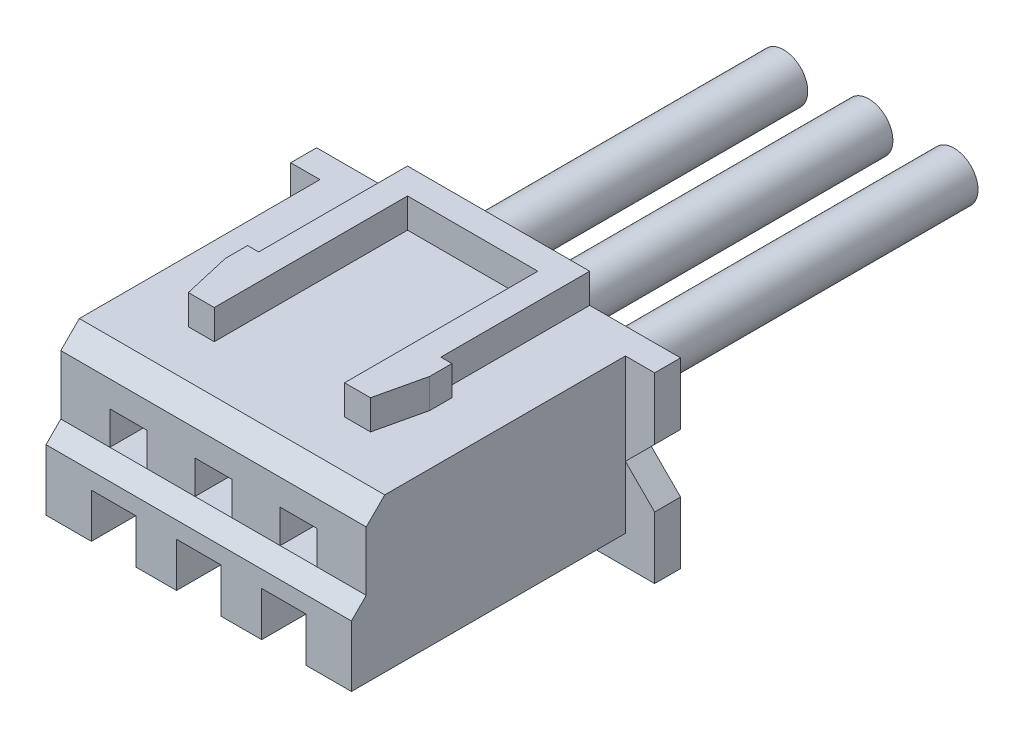
from build123d import *

# Parameters (mm, degrees)
ESQUISSE1_W               = 8.25
ESQUISSE1_H               = 4.15
ESQUISSE1_W_2             = 1
ESQUISSE1_H_2             = 0.9
BOSS_EXTRU_1_DEPTH        = 8.1
ESQUISSE2_W               = 5.6
ESQUISSE2_H               = 0.9
BOSS_EXTRU_2_DEPTH        = 0.7
ENL_V_MAT_EXTRU_1_DEPTH   = 6.6
ENL_V_MAT_EXTRU_2_DEPTH   = 10.04
ESQUISSE6_W               = 1.2
ESQUISSE6_H               = 1.2
ENL_V_MAT_EXTRU_3_DEPTH   = 3.1
BOSS_EXTRU_3_DEPTH        = 0.8
ESQUISSE8_R               = 0.65
BOSS_EXTRU_4_DEPTH        = 10
BOSS_EXTRU_4_DEPTH_BACK   = 2
BOSS_EXTRU_4_2_DEPTH      = 10
BOSS_EXTRU_4_2_DEPTH_BACK = 2
BOSS_EXTRU_4_3_DEPTH      = 10
BOSS_EXTRU_4_3_DEPTH_BACK = 2


with BuildPart() as part:
    # Esquisse1 → Boss.-Extru.1 (new body)
    with BuildSketch(Plane.XY):
        with Locations((0, -0.425)):
            Rectangle(ESQUISSE1_W, ESQUISSE1_H)
        Rectangle(ESQUISSE1_W_2, ESQUISSE1_H_2, mode=Mode.SUBTRACT)
        with Locations((-2.3, 0)):
            Rectangle(ESQUISSE1_W_2, ESQUISSE1_H_2, mode=Mode.SUBTRACT)
        with Locations((2.3, 0)):
            Rectangle(ESQUISSE1_W_2, ESQUISSE1_H_2, mode=Mode.SUBTRACT)
    extrude(amount=-BOSS_EXTRU_1_DEPTH)

    # Esquisse2 → Boss.-Extru.2 (add)
    with BuildSketch(Plane(origin=(0, 0, -8.1), x_dir=(-1, 0, 0), z_dir=(0, 0, -1))):
        Polygon((-4.915, 1.65), (4.915, 1.65), (4.915, -3.28), (-4.915, -3.28), (-4.915, -1.605), (-4.125, -0.815), (-4.915, -0.025), align=None)
        Rectangle(ESQUISSE2_W, ESQUISSE2_H, mode=Mode.SUBTRACT)
    extrude(amount=-BOSS_EXTRU_2_DEPTH)

    # Esquisse3 → Enlèv. mat.-Extru.1 (cut)
    with BuildSketch(Plane(origin=(0, 0, -8.1), x_dir=(-1, 0, 0), z_dir=(0, 0, -1))):
        Polygon((0.5, -1.6), (0.95, -1.6), (0.95, 1.05), (-0.95, 1.05), (-0.95, -1.6), (-0.5, -1.6), (-0.5, -1.9), (0.5, -1.9), align=None)
        Polygon((-1.8, -1.6), (-1.35, -1.6), (-1.35, 1.05), (-3.25, 1.05), (-3.25, -1.6), (-2.8, -1.6), (-2.8, -1.9), (-1.8, -1.9), align=None)
        Polygon((2.8, -1.6), (3.25, -1.6), (3.25, 1.05), (1.35, 1.05), (1.35, -1.6), (1.8, -1.6), (1.8, -1.9), (2.8, -1.9), align=None)
    extrude(amount=-ENL_V_MAT_EXTRU_1_DEPTH, mode=Mode.SUBTRACT)

    # Esquisse4 → Enlèv. mat.-Extru.2 (cut, through all)
    with BuildSketch(Plane(origin=(4.125, 0, 0), x_dir=(0, 0, -1), z_dir=(1, 0, 0))):
        Polygon((0, -0.85), (0.4, -0.45), (0.4, 1.15), (0.9, 1.65), (0, 1.65), align=None)
    extrude(amount=-ENL_V_MAT_EXTRU_2_DEPTH, mode=Mode.SUBTRACT)

    # Esquisse6 → Enlèv. mat.-Extru.3 (cut)
    with BuildSketch(Plane.XY):
        with Locations((-2.3, -1.9)):
            Rectangle(ESQUISSE6_W, ESQUISSE6_H)
        with Locations((0, -1.9)):
            Rectangle(ESQUISSE6_W, ESQUISSE6_H)
        with Locations((2.3, -1.9)):
            Rectangle(ESQUISSE6_W, ESQUISSE6_H)
    extrude(amount=-ENL_V_MAT_EXTRU_3_DEPTH, mode=Mode.SUBTRACT)

    # Esquisse7 → Boss.-Extru.3 (add)
    with BuildSketch(Plane(origin=(0, 1.65, 0), x_dir=(1, 0, 0), z_dir=(0, 1, 0))):
        Polygon((-2.46, 8.1), (2.46, 8.1), (2.46, 4.08), (2.76, 4.08), (2.76, 3.48), (2.46, 2.18), (1.76, 2.18), (1.76, 7.4), (-1.76, 7.4), (-1.76, 2.18), (-2.46, 2.18), (-2.76, 3.48), (-2.76, 4.08), (-2.46, 4.08), align=None)
    extrude(amount=BOSS_EXTRU_3_DEPTH)


with BuildPart() as body_2:
    # Esquisse8 → Boss.-Extru.4 (new body, two sides)
    with BuildSketch(Plane(origin=(0, 0, -8.1), x_dir=(-1, 0, 0), z_dir=(0, 0, -1))) as boss_extru_4_sk:
        with Locations((0, -0.4)):
            Circle(ESQUISSE8_R)
    extrude(amount=BOSS_EXTRU_4_DEPTH)
    extrude(boss_extru_4_sk.sketch, amount=-BOSS_EXTRU_4_DEPTH_BACK)


with BuildPart() as body_3:
    # Esquisse8 → Boss.-Extru.4 2 (new body, two sides)
    with BuildSketch(Plane(origin=(0, 0, -8.1), x_dir=(-1, 0, 0), z_dir=(0, 0, -1))) as boss_extru_4_2_sk:
        with Locations((-2.3, -0.4)):
            Circle(ESQUISSE8_R)
    extrude(amount=BOSS_EXTRU_4_2_DEPTH)
    extrude(boss_extru_4_2_sk.sketch, amount=-BOSS_EXTRU_4_2_DEPTH_BACK)


with BuildPart() as body_4:
    # Esquisse8 → Boss.-Extru.4 3 (new body, two sides)
    with BuildSketch(Plane(origin=(0, 0, -8.1), x_dir=(-1, 0, 0), z_dir=(0, 0, -1))) as boss_extru_4_3_sk:
        with Locations((2.3, -0.4)):
            Circle(ESQUISSE8_R)
    extrude(amount=BOSS_EXTRU_4_3_DEPTH)
    extrude(boss_extru_4_3_sk.sketch, amount=-BOSS_EXTRU_4_3_DEPTH_BACK)


solid = Compound([part.part, body_2.part, body_3.part, body_4.part])
